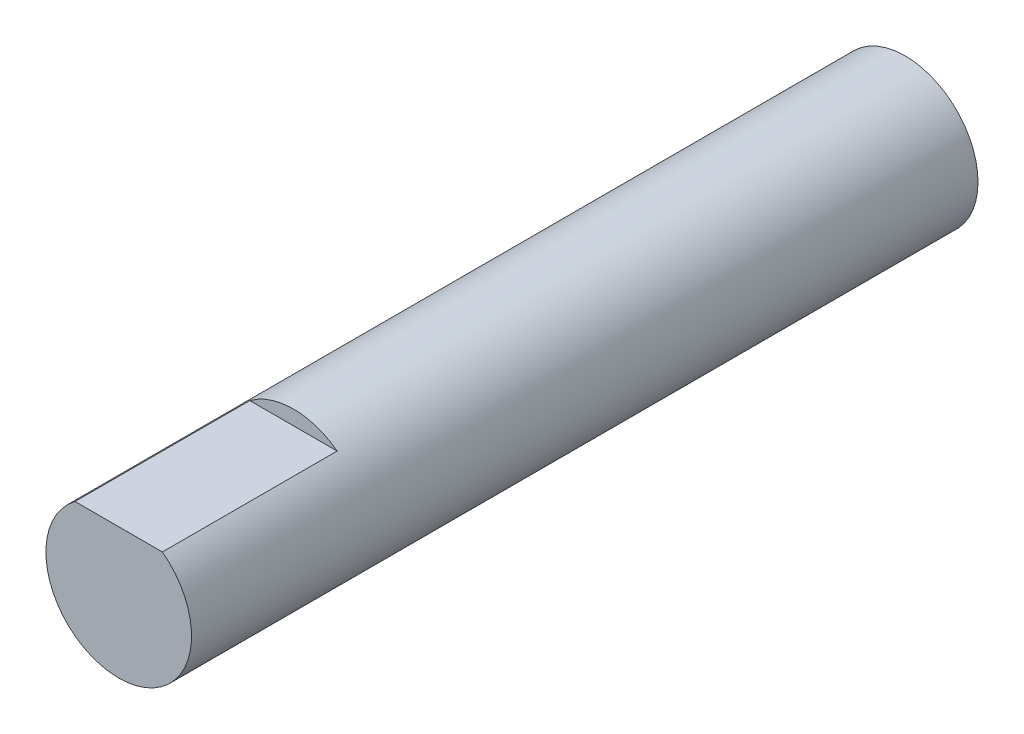
from build123d import *

# Parameters (mm, degrees)
SKETCH1_R           = 2.5
BOSS_EXTRUDE1_DEPTH = 27
CUT_EXTRUDE1_DEPTH  = 6


with BuildPart() as part:
    # Sketch1 → Boss-Extrude1 (new body)
    with BuildSketch(Plane.XY):
        Circle(SKETCH1_R)
    extrude(amount=BOSS_EXTRUDE1_DEPTH)

    # Sketch2 → Cut-Extrude1 (cut)
    with BuildSketch(Plane.XY.offset(27)):
        Polygon((-23.541594579, 2), (-1.5, 2), (1.5, 2), (23.541594579, 2), (23.541594579, 46.083189158), (-23.541594579, 46.083189158), align=None)
    extrude(amount=-CUT_EXTRUDE1_DEPTH, mode=Mode.SUBTRACT)


solid = part.part
